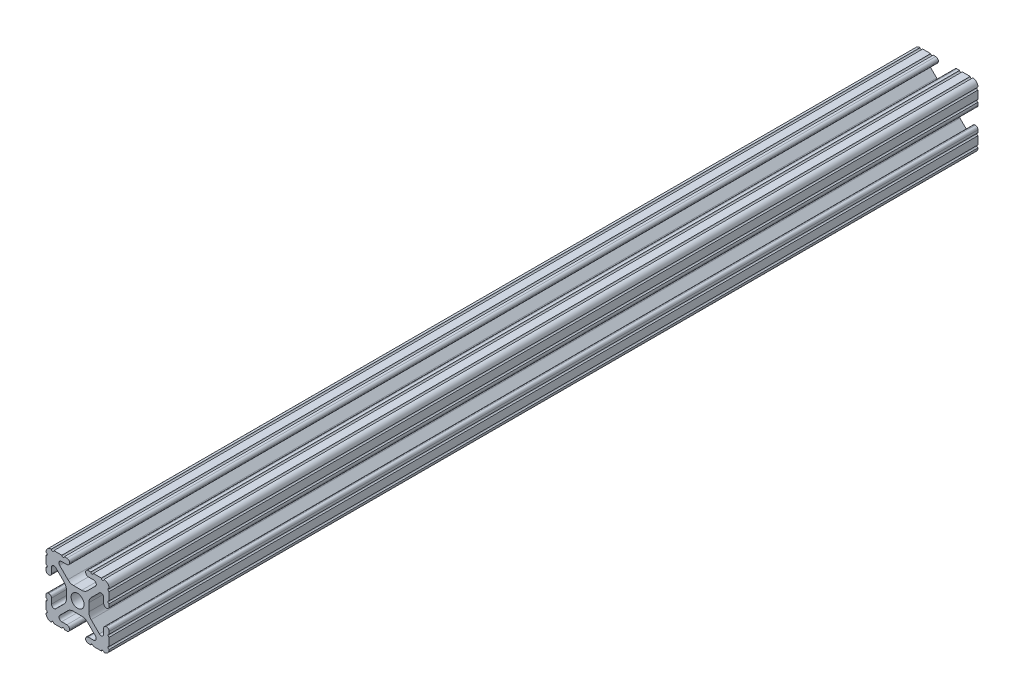
from build123d import *

# Parameters (mm, degrees)
SKETCH1_R           = 2.6035
BOSS_EXTRUDE1_DEPTH = 174.625


with BuildPart() as part:
    # Sketch1 → Boss-Extrude1 (new body, symmetric)
    with BuildSketch(Plane.XY):
        with BuildLine():
            Line((-7.179650497, -8.645192506), (-3.952270251, -5.423690499))
            ThreePointArc((-3.952270251, -5.423690499), (-2.922936451, -4.736929036), (-1.709253557, -4.4958))
            Line((-1.709253557, -4.4958), (1.709253557, -4.4958))
            ThreePointArc((1.709253557, -4.4958), (2.922936451, -4.736929036), (3.952270251, -5.423690499))
            Line((3.952270251, -5.423690499), (7.179650497, -8.645192506))
            ThreePointArc((7.179650497, -8.645192506), (7.41473083, -9.822813117), (6.416408329, -10.4902))
            Line((6.416408329, -10.4902), (4.287512407, -10.4902))
            ThreePointArc((4.287512407, -10.4902), (3.54574862, -10.79744862), (3.2385, -11.539212407))
            Line((3.2385, -11.539212407), (3.2385, -11.650987593))
            ThreePointArc((3.2385, -11.650987593), (3.54574862, -12.39275138), (4.287512407, -12.7))
            Line((4.287512407, -12.7), (5.317126718, -12.7))
            ThreePointArc((5.317126718, -12.7), (5.825126718, -12.192), (6.333126718, -12.7))
            Line((6.333126718, -12.7), (9.550443118, -12.7))
            ThreePointArc((9.550443118, -12.7), (10.058366869, -12.192000006), (10.566443095, -12.699847501))
            ThreePointArc((10.566443095, -12.699847501), (12.082537762, -12.08250727), (12.699846982, -10.566399977))
            ThreePointArc((12.699846982, -10.566399977), (12.192000006, -10.058323491), (12.7, -9.5504))
            Line((12.7, -9.5504), (12.7, -6.3330836))
            ThreePointArc((12.7, -6.3330836), (12.192, -5.8250836), (12.7, -5.3170836))
            Line((12.7, -5.3170836), (12.7, -4.287469289))
            ThreePointArc((12.7, -4.287469289), (12.39275138, -3.545705502), (11.650987593, -3.238456882))
            Line((11.650987593, -3.238456882), (11.539212407, -3.238456882))
            ThreePointArc((11.539212407, -3.238456882), (10.79744862, -3.545705502), (10.4902, -4.287469289))
            Line((10.4902, -4.287469289), (10.4902, -6.402089023))
            ThreePointArc((10.4902, -6.402089023), (9.856505071, -7.351067942), (8.737131347, -7.129408934))
            Line((8.737131347, -7.129408934), (5.441005833, -3.840816462))
            ThreePointArc((5.441005833, -3.840816462), (4.750877967, -2.809883091), (4.5085, -1.593185507))
            Line((4.5085, -1.593185507), (4.5085, 1.593185507))
            ThreePointArc((4.5085, 1.593185507), (4.750877967, 2.809883091), (5.441005833, 3.840816462))
            Line((5.441005833, 3.840816462), (8.737131347, 7.129408934))
            ThreePointArc((8.737131347, 7.129408934), (9.856505071, 7.351067942), (10.4902, 6.402089023))
            Line((10.4902, 6.402089023), (10.4902, 4.287469289))
            ThreePointArc((10.4902, 4.287469289), (10.79744862, 3.545705502), (11.539212407, 3.238456882))
            Line((11.539212407, 3.238456882), (11.650987593, 3.238456882))
            ThreePointArc((11.650987593, 3.238456882), (12.39275138, 3.545705502), (12.7, 4.287469289))
            Line((12.7, 4.287469289), (12.7, 5.3170836))
            ThreePointArc((12.7, 5.3170836), (12.192, 5.8250836), (12.7, 6.3330836))
            Line((12.7, 6.3330836), (12.7, 9.5504))
            ThreePointArc((12.7, 9.5504), (12.192000006, 10.058323491), (12.699846982, 10.566399977))
            ThreePointArc((12.699846982, 10.566399977), (12.082537762, 12.08250727), (10.566443095, 12.699847501))
            ThreePointArc((10.566443095, 12.699847501), (10.058366869, 12.192000006), (9.550443118, 12.7))
            Line((9.550443118, 12.7), (6.333126718, 12.7))
            ThreePointArc((6.333126718, 12.7), (5.825126718, 12.192), (5.317126718, 12.7))
            Line((5.317126718, 12.7), (4.287512407, 12.7))
            ThreePointArc((4.287512407, 12.7), (3.54574862, 12.39275138), (3.2385, 11.650987593))
            Line((3.2385, 11.650987593), (3.2385, 11.539212407))
            ThreePointArc((3.2385, 11.539212407), (3.54574862, 10.79744862), (4.287512407, 10.4902))
            Line((4.287512407, 10.4902), (6.476788598, 10.4902))
            ThreePointArc((6.476788598, 10.4902), (7.432222385, 9.85140422), (7.207036008, 8.724370562))
            Line((7.207036008, 8.724370562), (3.898272566, 5.423169045))
            ThreePointArc((3.898272566, 5.423169045), (2.869120213, 4.736787962), (1.655778399, 4.4958))
            Line((1.655778399, 4.4958), (-1.655778399, 4.4958))
            ThreePointArc((-1.655778399, 4.4958), (-2.869120213, 4.736787962), (-3.898272566, 5.423169045))
            Line((-3.898272566, 5.423169045), (-7.207036008, 8.724370562))
            ThreePointArc((-7.207036008, 8.724370562), (-7.432222385, 9.85140422), (-6.476788598, 10.4902))
            Line((-6.476788598, 10.4902), (-4.287512407, 10.4902))
            ThreePointArc((-4.287512407, 10.4902), (-3.54574862, 10.79744862), (-3.2385, 11.539212407))
            Line((-3.2385, 11.539212407), (-3.2385, 11.650987593))
            ThreePointArc((-3.2385, 11.650987593), (-3.54574862, 12.39275138), (-4.287512407, 12.7))
            Line((-4.287512407, 12.7), (-5.317126718, 12.7))
            ThreePointArc((-5.317126718, 12.7), (-5.825126718, 12.192), (-6.333126718, 12.7))
            Line((-6.333126718, 12.7), (-9.550443118, 12.7))
            ThreePointArc((-9.550443118, 12.7), (-10.058366869, 12.192000006), (-10.566443095, 12.699847501))
            ThreePointArc((-10.566443095, 12.699847501), (-12.082537762, 12.08250727), (-12.699846982, 10.566399977))
            ThreePointArc((-12.699846982, 10.566399977), (-12.192000006, 10.058323491), (-12.7, 9.5504))
            Line((-12.7, 9.5504), (-12.7, 6.3330836))
            ThreePointArc((-12.7, 6.3330836), (-12.192, 5.8250836), (-12.7, 5.3170836))
            Line((-12.7, 5.3170836), (-12.7, 4.287469289))
            ThreePointArc((-12.7, 4.287469289), (-12.39275138, 3.545705502), (-11.650987593, 3.238456882))
            Line((-11.650987593, 3.238456882), (-11.539212407, 3.238456882))
            ThreePointArc((-11.539212407, 3.238456882), (-10.79744862, 3.545705502), (-10.4902, 4.287469289))
            Line((-10.4902, 4.287469289), (-10.4902, 6.402089023))
            ThreePointArc((-10.4902, 6.402089023), (-9.856505071, 7.351067942), (-8.737131347, 7.129408934))
            Line((-8.737131347, 7.129408934), (-5.441005833, 3.840816462))
            ThreePointArc((-5.441005833, 3.840816462), (-4.750877967, 2.809883091), (-4.5085, 1.593185507))
            Line((-4.5085, 1.593185507), (-4.5085, -1.593185507))
            ThreePointArc((-4.5085, -1.593185507), (-4.750877967, -2.809883091), (-5.441005833, -3.840816462))
            Line((-5.441005833, -3.840816462), (-8.737131347, -7.129408934))
            ThreePointArc((-8.737131347, -7.129408934), (-9.856505071, -7.351067942), (-10.4902, -6.402089023))
            Line((-10.4902, -6.402089023), (-10.4902, -4.287469289))
            ThreePointArc((-10.4902, -4.287469289), (-10.79744862, -3.545705502), (-11.539212407, -3.238456882))
            Line((-11.539212407, -3.238456882), (-11.650987593, -3.238456882))
            ThreePointArc((-11.650987593, -3.238456882), (-12.39275138, -3.545705502), (-12.7, -4.287469289))
            Line((-12.7, -4.287469289), (-12.7, -5.3170836))
            ThreePointArc((-12.7, -5.3170836), (-12.192, -5.8250836), (-12.7, -6.3330836))
            Line((-12.7, -6.3330836), (-12.7, -9.5504))
            ThreePointArc((-12.7, -9.5504), (-12.192000006, -10.058323491), (-12.699846982, -10.566399977))
            ThreePointArc((-12.699846982, -10.566399977), (-12.082537762, -12.08250727), (-10.566443095, -12.699847501))
            ThreePointArc((-10.566443095, -12.699847501), (-10.058366869, -12.192000006), (-9.550443118, -12.7))
            Line((-9.550443118, -12.7), (-6.333126718, -12.7))
            ThreePointArc((-6.333126718, -12.7), (-5.825126718, -12.192), (-5.317126718, -12.7))
            Line((-5.317126718, -12.7), (-4.287512407, -12.7))
            ThreePointArc((-4.287512407, -12.7), (-3.54574862, -12.39275138), (-3.2385, -11.650987593))
            Line((-3.2385, -11.650987593), (-3.2385, -11.539212407))
            ThreePointArc((-3.2385, -11.539212407), (-3.54574862, -10.79744862), (-4.287512407, -10.4902))
            Line((-4.287512407, -10.4902), (-6.416408329, -10.4902))
            ThreePointArc((-6.416408329, -10.4902), (-7.41473083, -9.822813117), (-7.179650497, -8.645192506))
        make_face()
        Circle(SKETCH1_R, mode=Mode.SUBTRACT)
    extrude(amount=BOSS_EXTRUDE1_DEPTH, both=True)


solid = part.part
